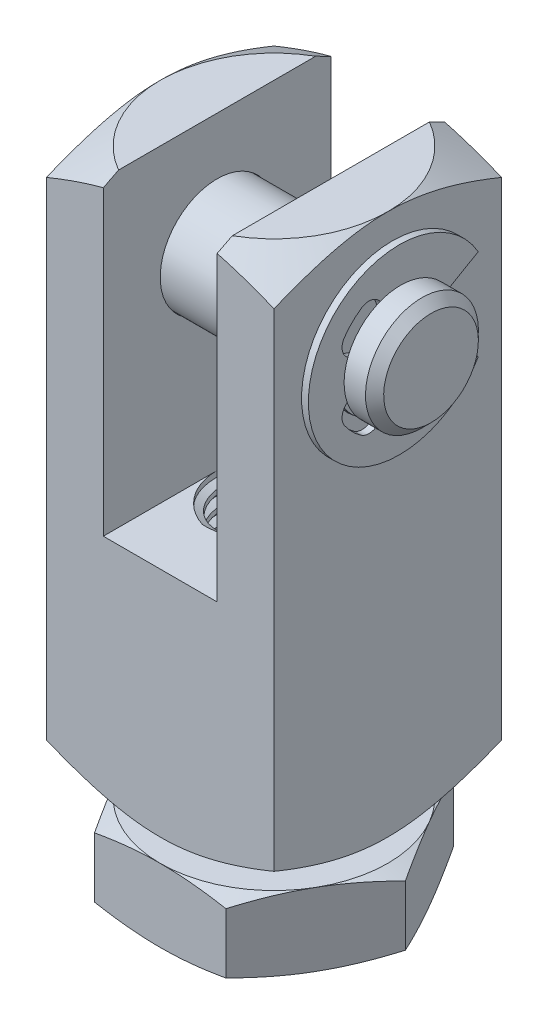
from build123d import *

# Parameters (mm, degrees)
SKETCH1_W               = 12.7
SKETCH1_H               = 30.226
EXTRUDE1_DEPTH          = 6.35
CUT_EXTRUDE1_DEPTH      = 32.531826398
CUT_EXTRUDE1_DEPTH_BACK = 32.531826398
SKETCH2_W               = 6.35
SKETCH2_H               = 17.272
SKETCH9_W               = 12.7
SKETCH9_H               = 3.175
SKETCH4_OUTSIDE_W       = 134.426
SKETCH4_OUTSIDE_H       = 134.426
SKETCH4_OUTSIDE_R       = 6.35
CUT_EXTRUDE3_DEPTH      = 32.531826398
CUT_EXTRUDE3_DRAFT      = -60
SKETCH5_OUTSIDE_W       = 134.426
SKETCH5_OUTSIDE_H       = 134.426
SKETCH5_OUTSIDE_R       = 6.35
CUT_EXTRUDE4_DEPTH      = 32.531826398
CUT_EXTRUDE4_DRAFT      = 60
SKETCH6_W               = 3.175
SKETCH6_H               = 12.954
LPATTERN1_COUNT         = 2
LPATTERN1_PITCH         = 0.907142857
LPATTERN1_COL_COUNT     = 14
LPATTERN1_COL_PITCH     = 0.907142857
EXTRUDE2_DEPTH          = 4.064
SKETCH12_W              = 3.175
SKETCH12_H              = 4.064
LPATTERN3_COUNT         = 2
LPATTERN3_PITCH         = 0.907142857
LPATTERN3_COL_COUNT     = 4
LPATTERN3_COL_PITCH     = 0.907142857
EXTRUDE3_DEPTH          = 0.1905


with BuildPart() as part:
    # Sketch1 → Extrude1 (new, symmetric)
    with BuildSketch(Plane.XY):
        with Locations((0, 15.113)):
            Rectangle(SKETCH1_W, SKETCH1_H)
    extrude(amount=EXTRUDE1_DEPTH, both=True)

    # Sketch2 → Cut-Extrude1 (cut, two sides: drawn at the far end of the back side and taken through both)
    with BuildSketch(Plane.XY.offset(-CUT_EXTRUDE1_DEPTH_BACK)):
        with Locations((0, 21.59)):
            Rectangle(SKETCH2_W, SKETCH2_H)
    extrude(amount=CUT_EXTRUDE1_DEPTH + CUT_EXTRUDE1_DEPTH_BACK, mode=Mode.SUBTRACT)

    # Sketch9 → Cut-Revolve3 (revolve, cut)
    with BuildSketch(Plane.XY, mode=Mode.PRIVATE) as cut_revolve3_sk:
        with Locations((0, 25.4635)):
            Rectangle(SKETCH9_W, SKETCH9_H)
    revolve(cut_revolve3_sk.sketch.rotate(Axis((-6.35, 23.876, 0), (-1, 0, 0)), 90), axis=Axis((-6.35, 23.876, 0), (-1, 0, 0)), mode=Mode.SUBTRACT)


with BuildPart() as cut_extrude3_tool:
    # Sketch4 outside → Cut-Extrude3 (with draft: the straight prism first)
    with BuildSketch(Plane(origin=(0, 30.226, 0), x_dir=(-1, 0, 0), z_dir=(0, 1, 0))):
        Rectangle(SKETCH4_OUTSIDE_W, SKETCH4_OUTSIDE_H)
        Circle(SKETCH4_OUTSIDE_R, mode=Mode.SUBTRACT)
    extrude(amount=-CUT_EXTRUDE3_DEPTH)
    # Cut-Extrude3: the draft: its side faces are tilted about the plane it starts from
    cut_extrude3_sides = [cut_extrude3_tool.faces().sort_by_distance(p)[0] for p in [
        (0, 13.960086801, -67.213),
        (-67.213, 13.960086801, 0),
        (0, 13.960086801, 67.213),
        (67.213, 13.960086801, 0),
        (6.35, 13.960086801, 0),
    ]]
    draft(cut_extrude3_sides, Plane(origin=(0, 30.226, 0), x_dir=(-1, 0, 0), z_dir=(0, 1, 0)), CUT_EXTRUDE3_DRAFT)


with BuildPart() as part_1:
    add(part.part)

    # Cut-Extrude3: cut by cut_extrude3_tool
    add(cut_extrude3_tool.part, mode=Mode.SUBTRACT)


with BuildPart() as cut_extrude4_tool:
    # Sketch5 outside → Cut-Extrude4 (with draft: the straight prism first)
    with BuildSketch(Plane(origin=(0, 0, 0), x_dir=(1, 0, 0), z_dir=(0, 1, 0))):
        Rectangle(SKETCH5_OUTSIDE_W, SKETCH5_OUTSIDE_H)
        Circle(SKETCH5_OUTSIDE_R, mode=Mode.SUBTRACT)
    extrude(amount=CUT_EXTRUDE4_DEPTH)
    # Cut-Extrude4: the draft: its side faces are tilted about the plane it starts from
    cut_extrude4_sides = [cut_extrude4_tool.faces().sort_by_distance(p)[0] for p in [
        (0, 16.265913199, 67.213),
        (67.213, 16.265913199, 0),
        (0, 16.265913199, -67.213),
        (-67.213, 16.265913199, 0),
        (-6.35, 16.265913199, 0),
    ]]
    draft(cut_extrude4_sides, Plane(origin=(0, 0, 0), x_dir=(1, 0, 0), z_dir=(0, 1, 0)), CUT_EXTRUDE4_DRAFT)


with BuildPart() as part_2:
    add(part_1.part)

    # Cut-Extrude4: cut by cut_extrude4_tool
    add(cut_extrude4_tool.part, mode=Mode.SUBTRACT)

    # Sketch8 → Cut-Revolve2 (revolve, cut)
    with BuildSketch(Plane.XY, mode=Mode.PRIVATE) as cut_revolve2_sk:
        Polygon((3.175, 0), (0, 1.833087105), (0, 0), align=None)
    revolve(cut_revolve2_sk.sketch.rotate(Axis((0, 1.833087105, 0), (0, -1, 0)), 216.045854382), axis=Axis((0, 1.833087105, 0), (0, -1, 0)), mode=Mode.SUBTRACT)


with BuildPart() as body_2:
    # Sketch6 → Revolve1 (revolve)
    with BuildSketch(Plane.XY, mode=Mode.PRIVATE) as revolve1_sk:
        with Locations((1.5875, 6.477)):
            Rectangle(SKETCH6_W, SKETCH6_H)
    revolve(revolve1_sk.sketch.rotate(Axis((0, 0, 0), (0, -1, 0)), 180), axis=Axis((0, 0, 0), (0, -1, 0)))

    # Sketch7 → Cut-Revolve1 (revolve, cut)
    with BuildSketch(Plane.XY, mode=Mode.PRIVATE) as cut_revolve1_sk:
        Polygon((-3.191036172, 0.112253202), (-3.303289373, 0.898025612), (-2.777128323, 0.686831268), (-2.74505598, 0.462324865), align=None)
    cut_revolve1 = revolve(cut_revolve1_sk.sketch.rotate(Axis((0.1384314, 0, 0), (-0.14142135623730961, 0.9899494936611666, 0)), 180), axis=Axis((0.1384314, 0, 0), (-0.14142135623730961, 0.9899494936611666, 0)), mode=Mode.SUBTRACT)

    # LPattern1: Cut-Revolve1 ×2
    with Locations(*[(0, -i * LPATTERN1_PITCH, 0) for i in range(1, LPATTERN1_COUNT)]):
        add(cut_revolve1, mode=Mode.SUBTRACT)

    # LPattern1 col: Cut-Revolve1 ×14
    with Locations(*[(0, i * LPATTERN1_COL_PITCH, 0) for i in range(1, LPATTERN1_COL_COUNT)]):
        add(cut_revolve1, mode=Mode.SUBTRACT)


with BuildPart() as part_3:
    add(part_2.part)

    # Combine1: cut body 2
    add(body_2.part, mode=Mode.SUBTRACT)


with BuildPart() as body_2_2:
    # Sketch10 → Extrude2 (new body)
    with BuildSketch(Plane(origin=(0, -1.27, 0), x_dir=(-1, 0, 0), z_dir=(0, 1, 0))):
        Polygon((-7.332348419, 0), (-3.666174209, -6.35), (3.666174209, -6.35), (7.332348419, 0), (3.666174209, 6.35), (-3.666174209, 6.35), align=None)
    extrude(amount=-EXTRUDE2_DEPTH)

    # Sketch11 → Cut-Revolve4 (revolve, cut)
    with BuildSketch(Plane.XY, mode=Mode.PRIVATE) as cut_revolve4_sk:
        Polygon((6.35, -1.27), (7.332348419, -1.27), (7.332348419, -1.627545584), align=None)
        Polygon((6.35, -5.334), (7.332348419, -5.334), (7.332348419, -4.976454416), align=None)
    revolve(cut_revolve4_sk.sketch.rotate(Axis((0, -1.27, 0), (0, -1, 0)), 216.045854382), axis=Axis((0, -1.27, 0), (0, -1, 0)), mode=Mode.SUBTRACT)

    # Cut-Extrude5 cone 1 section (through the dimple's axis) → Cut-Extrude5 (revolve, cut)
    with BuildSketch(Plane(origin=(0, -1.27, 0), x_dir=(0, 0, 1), z_dir=(1, 0, 0))):
        Polygon((0, 0), (3.175, 0), (0, 1.833087105), align=None)
    revolve(axis=Axis((0, -1.27, 0), (0, -1, 0)), mode=Mode.SUBTRACT)

    # Cut-Extrude6 cone 1 section (through the dimple's axis) → Cut-Extrude6 (revolve, cut)
    with BuildSketch(Plane(origin=(0, -5.334, 0), x_dir=(0, 0, -1), z_dir=(1, 0, 0))):
        Polygon((0, 0), (3.175, 0), (0, 1.833087105), align=None)
    revolve(axis=Axis((0, -5.334, 0), (0, 1, 0)), mode=Mode.SUBTRACT)


with BuildPart() as body_3:
    # Sketch12 → Revolve2 (revolve)
    with BuildSketch(Plane.XY, mode=Mode.PRIVATE) as revolve2_sk:
        with Locations((1.5875, -3.302)):
            Rectangle(SKETCH12_W, SKETCH12_H)
    revolve(revolve2_sk.sketch.rotate(Axis((0, -1.27, 0), (0, -1, 0)), 216.045854382), axis=Axis((0, -1.27, 0), (0, -1, 0)))

    # Sketch13 → Cut-Revolve5 (revolve, cut)
    with BuildSketch(Plane.XY, mode=Mode.PRIVATE) as cut_revolve5_sk:
        Polygon((-3.191036172, -5.221746798), (-3.303289373, -4.435974388), (-2.777128323, -4.647168732), (-2.74505598, -4.871675135), align=None)
    cut_revolve5 = revolve(cut_revolve5_sk.sketch.rotate(Axis((0.1384314, -5.334, 0), (-0.14142135623730973, 0.9899494936611666, 0)), 180), axis=Axis((0.1384314, -5.334, 0), (-0.14142135623730973, 0.9899494936611666, 0)), mode=Mode.SUBTRACT)

    # LPattern3: Cut-Revolve5 ×2
    with Locations(*[(0, -i * LPATTERN3_PITCH, 0) for i in range(1, LPATTERN3_COUNT)]):
        add(cut_revolve5, mode=Mode.SUBTRACT)

    # LPattern3 col: Cut-Revolve5 ×4
    with Locations(*[(0, i * LPATTERN3_COL_PITCH, 0) for i in range(1, LPATTERN3_COL_COUNT)]):
        add(cut_revolve5, mode=Mode.SUBTRACT)


with BuildPart() as body_2_2_1:
    add(body_2_2.part)

    # Combine2: cut body 3
    add(body_3.part, mode=Mode.SUBTRACT)


with BuildPart() as body_3_2:
    # Sketch16 → Revolve3 (revolve)
    with BuildSketch(Plane.XY, mode=Mode.PRIVATE) as revolve3_sk:
        Polygon((-8.255, 27.0256), (-7.0612, 27.0256), (-7.0612, 26.2636), (-6.5532, 26.2636), (-6.5532, 27.0256), (6.5532, 27.0256), (6.5532, 26.2636), (7.0612, 26.2636), (7.0612, 27.0256), (8.255, 27.0256), (8.763, 26.5176), (8.763, 23.876), (-8.763, 23.876), (-8.763, 26.5176), align=None)
    revolve(revolve3_sk.sketch.rotate(Axis((8.763, 23.876, 0), (1, 0, 0)), 180), axis=Axis((8.763, 23.876, 0), (1, 0, 0)))

    # Sketch17 → Extrude3 (add, symmetric)
    with BuildSketch(Plane(origin=(-6.8072, 0, 0), x_dir=(0, 0, -1), z_dir=(1, 0, 0))):
        with BuildLine():
            Line((2.067722254, 25.0698), (4.399409051, 26.416))
            ThreePointArc((4.399409051, 26.416), (-5.08, 23.876), (4.399409051, 21.336))
            Line((4.399409051, 21.336), (2.067722254, 22.6822))
            ThreePointArc((2.067722254, 22.6822), (0.816607294, 21.632389899), (-0.816607294, 21.632389899))
            Line((-0.816607294, 21.632389899), (-0.982434703, 21.176782837))
            ThreePointArc((-0.982434703, 21.176782837), (-1.468436992, 20.710956047), (-2.133988296, 20.812120695))
            ThreePointArc((-2.133988296, 20.812120695), (-2.6401953, 21.2358047), (-3.063879305, 21.742011704))
            ThreePointArc((-3.063879305, 21.742011704), (-3.165043953, 22.407563008), (-2.699217163, 22.893565297))
            Line((-2.699217163, 22.893565297), (-2.243610101, 23.059392706))
            ThreePointArc((-2.243610101, 23.059392706), (-2.3876, 23.876), (-2.243610101, 24.692607294))
            Line((-2.243610101, 24.692607294), (-2.699217163, 24.858434703))
            ThreePointArc((-2.699217163, 24.858434703), (-3.165043953, 25.344436992), (-3.063879305, 26.009988296))
            ThreePointArc((-3.063879305, 26.009988296), (-2.6401953, 26.5161953), (-2.133988296, 26.939879305))
            ThreePointArc((-2.133988296, 26.939879305), (-1.468436992, 27.041043953), (-0.982434703, 26.575217163))
            Line((-0.982434703, 26.575217163), (-0.816607294, 26.119610101))
            ThreePointArc((-0.816607294, 26.119610101), (0.816607294, 26.119610101), (2.067722254, 25.0698))
        make_face()
    extrude3 = extrude(amount=EXTRUDE3_DEPTH, both=True)

    # Mirror1: Extrude3 across plane
    add(extrude3.mirror(Plane(origin=(0, 0, 0), x_dir=(0, 0, 1), z_dir=(1, 0, 0))))


solid = Compound([part_3.part, body_2_2_1.part, body_3_2.part])
